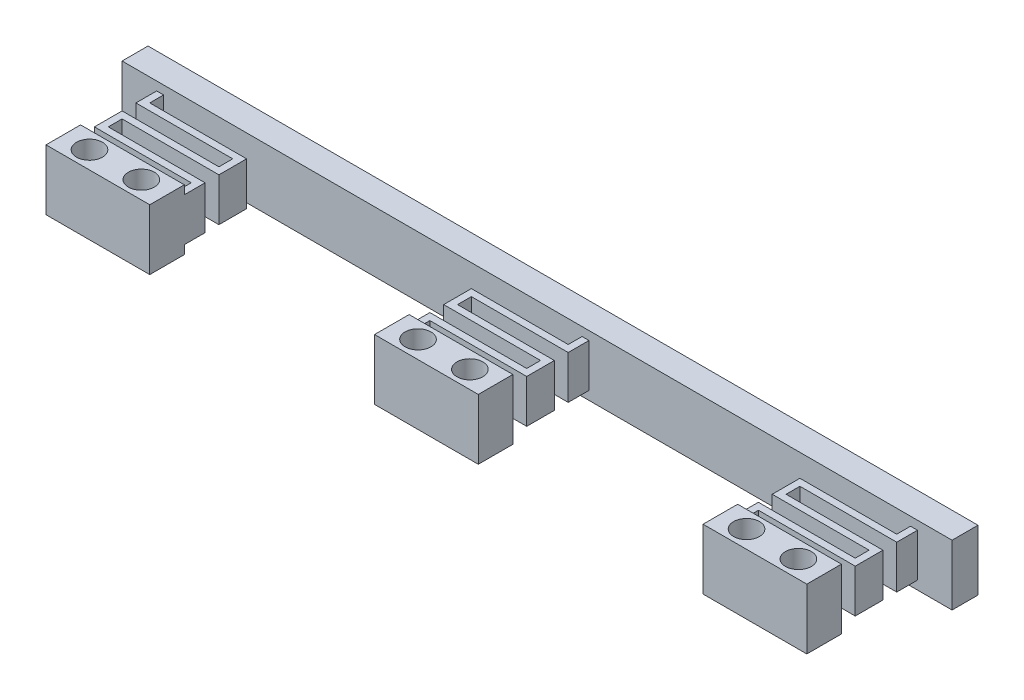
from build123d import *

# Parameters (mm, degrees)
SKETCH_1_W          = 96
SKETCH_1_H          = 7
EXTRUDE_1_DEPTH     = 3
EXTRUDE_2_DEPTH     = 7
EXTRUDE_2_2_DEPTH   = 7
EXTRUDE_2_3_DEPTH   = 7
SKETCH_3_R          = 1.5
CUT_EXTRUDE_1_DEPTH = 10
SKETCH_4_W          = 8.8
SKETCH_4_H          = 1.825750082
SKETCH_4_H_2        = 1.684722937
CUT_EXTRUDE_2_DEPTH = 107


with BuildPart() as part:
    # 스케치1 → 보스-돌출1 (new body)
    with BuildSketch(Plane.XY):
        Rectangle(SKETCH_1_W, SKETCH_1_H)
    extrude(amount=EXTRUDE_1_DEPTH)


with BuildPart() as body_2:
    # 스케치2 → 보스-돌출2 (new body)
    with BuildSketch(Plane(origin=(0, 3.5, 0), x_dir=(1, 0, 0), z_dir=(0, 1, 0))):
        Polygon((-44, -3), (-44, -5.4), (-32.795959597, -5.4), (-32.8, -7), (-44, -7), (-44, -10.2), (-32.8, -10.2), (-32.8, -11.8), (-44, -11.8), (-44, -15.8), (-32, -15.8), (-32, -9.4), (-43.2, -9.4), (-43.2, -7.8), (-32, -7.8), (-32, -4.6), (-43.2, -4.6), (-43.2, -3), align=None)
    extrude(amount=-EXTRUDE_2_DEPTH)


with BuildPart() as body_3:
    # 스케치2 → Extrude 2 2 (new body)
    with BuildSketch(Plane(origin=(0, 3.5, 0), x_dir=(1, 0, 0), z_dir=(0, 1, 0))):
        Polygon((44, -3), (43.2, -3), (43.2, -4.6), (32, -4.6), (32, -7.8), (43.2, -7.8), (43.2, -9.4), (32, -9.4), (32, -15.8), (44, -15.8), (44, -11.8), (32.8, -11.8), (32.8, -10.2), (44, -10.2), (44, -7), (32.8, -7), (32.8, -5.4), (44, -5.4), align=None)
    extrude(amount=-EXTRUDE_2_2_DEPTH)


with BuildPart() as body_4:
    # 스케치2 → Extrude 2 3 (new body)
    with BuildSketch(Plane(origin=(0, 3.5, 0), x_dir=(1, 0, 0), z_dir=(0, 1, 0))):
        Polygon((6, -3), (5.2, -3), (5.2, -4.6), (-6, -4.6), (-6, -7.8), (5.2, -7.8), (5.2, -9.4), (-6, -9.4), (-6, -15.8), (6, -15.8), (6, -11.8), (-5.2, -11.8), (-5.2, -10.2), (6, -10.2), (6, -7), (-5.2, -7), (-5.2, -5.4), (6, -5.4), align=None)
    extrude(amount=-EXTRUDE_2_3_DEPTH)


with BuildPart() as cut_extrude_1_tool:
    # 스케치3 → 컷-돌출1 (new body)
    with BuildSketch(Plane(origin=(0, 3.5, 0), x_dir=(1, 0, 0), z_dir=(0, 1, 0))):
        with Locations((-41, -13.771363705)):
            Circle(SKETCH_3_R)
        with Locations((-35, -13.771363705)):
            Circle(SKETCH_3_R)
        with Locations((-3, -13.771363705)):
            Circle(SKETCH_3_R)
        with Locations((3, -13.771363705)):
            Circle(SKETCH_3_R)
        with Locations((35, -13.771363705)):
            Circle(SKETCH_3_R)
        with Locations((41, -13.771363705)):
            Circle(SKETCH_3_R)
    extrude(amount=-CUT_EXTRUDE_1_DEPTH)


with BuildPart() as body_2_1:
    add(body_2.part)

    # 컷-돌출1: cut by cut_extrude_1_tool
    add(cut_extrude_1_tool.part, mode=Mode.SUBTRACT)


with BuildPart() as body_3_1:
    add(body_3.part)

    # 컷-돌출1: cut by cut_extrude_1_tool
    add(cut_extrude_1_tool.part, mode=Mode.SUBTRACT)


with BuildPart() as body_4_1:
    add(body_4.part)

    # 컷-돌출1: cut by cut_extrude_1_tool
    add(cut_extrude_1_tool.part, mode=Mode.SUBTRACT)


with BuildPart() as cut_extrude_2_tool:
    # 스케치4 → 컷-돌출2 (new body)
    with BuildSketch(Plane.ZY.offset(48)):
        with Locations((7.4, 3.412875041)):
            Rectangle(SKETCH_4_W, SKETCH_4_H)
        with Locations((7.4, -3.342361469)):
            Rectangle(SKETCH_4_W, SKETCH_4_H_2)
    extrude(amount=-CUT_EXTRUDE_2_DEPTH)


with BuildPart() as body_2_2:
    add(body_2_1.part)

    # 컷-돌출2: cut by cut_extrude_2_tool
    add(cut_extrude_2_tool.part, mode=Mode.SUBTRACT)


with BuildPart() as body_3_2:
    add(body_3_1.part)

    # 컷-돌출2: cut by cut_extrude_2_tool
    add(cut_extrude_2_tool.part, mode=Mode.SUBTRACT)


with BuildPart() as body_4_2:
    add(body_4_1.part)

    # 컷-돌출2: cut by cut_extrude_2_tool
    add(cut_extrude_2_tool.part, mode=Mode.SUBTRACT)


solid = Compound([part.part, body_2_2.part, body_3_2.part, body_4_2.part])
